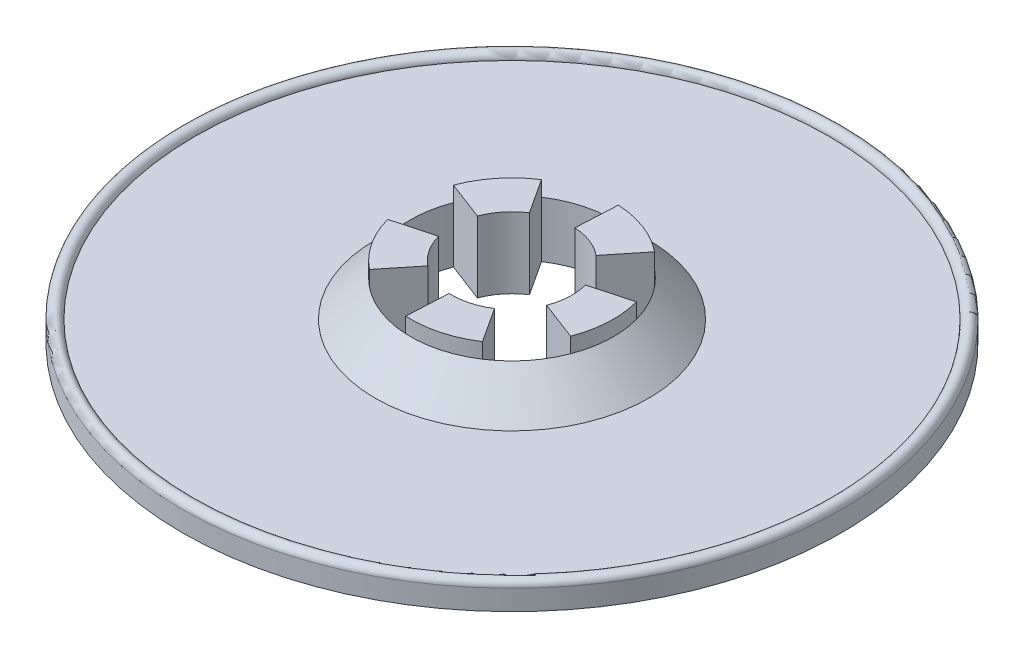
from build123d import *

# Parameters (mm, degrees)
SKETCH1_R           = 41.275
BOSS_EXTRUDE1_DEPTH = 2.54
SKETCH6_R           = 12.7
BOSS_EXTRUDE3_DEPTH = 6.35
CHAMFER2_SIZE       = 4.445
CUT_EXTRUDE2_DEPTH  = 9.89


with BuildPart() as part:
    # Sketch1 → Boss-Extrude1 (new body)
    with BuildSketch(Plane(origin=(0, 0, 0), x_dir=(1, 0, 0), z_dir=(0, 1, 0))):
        Circle(SKETCH1_R)
    extrude(amount=BOSS_EXTRUDE1_DEPTH)

    # Sketch6 → Boss-Extrude3 (add)
    with BuildSketch(Plane(origin=(0, 2.54, 0), x_dir=(1, 0, 0), z_dir=(0, 1, 0))):
        Circle(SKETCH6_R)
    extrude(amount=BOSS_EXTRUDE3_DEPTH)

    # Chamfer2
    chamfer2_edges = [part.edges().sort_by_distance(p)[0] for p in [
        (-12.7, 2.54, 0),
    ]]
    chamfer(chamfer2_edges, length=CHAMFER2_SIZE)

    # Sketch4 → Cut-Extrude2 (cut, through all)
    with BuildSketch(Plane.XZ):
        with BuildLine():
            ThreePointArc((11.86615569, 4.52596389), (9.886784934, 7.971291217), (6.939626784, 10.636333019))
            Line((6.939626784, 10.636333019), (4.098204794, 6.281299027))
            ThreePointArc((4.098204794, 6.281299027), (1.956596228, 7.240285298), (-0.376537609, 7.490541998))
            Line((-0.376537609, 7.490541998), (-0.637603684, 12.683984451))
            ThreePointArc((-0.637603684, 12.683984451), (-4.52596389, 11.86615569), (-7.971291217, 9.886784934))
            Line((-7.971291217, 9.886784934), (-4.707455443, 5.83865252))
            ThreePointArc((-4.707455443, 5.83865252), (-6.281299027, 4.098204794), (-7.240285298, 1.956596228))
            Line((-7.240285298, 1.956596228), (-12.260216438, 3.313169613))
            ThreePointArc((-12.260216438, 3.313169613), (-12.683984451, -0.637603684), (-11.86615569, -4.52596389))
            Line((-11.86615569, -4.52596389), (-7.007572258, -2.672813321))
            ThreePointArc((-7.007572258, -2.672813321), (-5.83865252, -4.707455443), (-4.098204794, -6.281299027))
            Line((-4.098204794, -6.281299027), (-6.939626784, -10.636333019))
            ThreePointArc((-6.939626784, -10.636333019), (-3.313169613, -12.260216438), (0.637603684, -12.683984451))
            Line((0.637603684, -12.683984451), (0.376537609, -7.490541998))
            ThreePointArc((0.376537609, -7.490541998), (2.672813321, -7.007572258), (4.707455443, -5.83865252))
            Line((4.707455443, -5.83865252), (7.971291217, -9.886784934))
            ThreePointArc((7.971291217, -9.886784934), (10.636333019, -6.939626784), (12.260216438, -3.313169613))
            Line((12.260216438, -3.313169613), (7.240285298, -1.956596228))
            ThreePointArc((7.240285298, -1.956596228), (7.490541998, 0.376537609), (7.007572258, 2.672813321))
            Line((7.007572258, 2.672813321), (11.86615569, 4.52596389))
        make_face()
    extrude(amount=-CUT_EXTRUDE2_DEPTH, mode=Mode.SUBTRACT)

    # Sketch7 → Revolve1 (revolve)
    with BuildSketch(Plane.XY):
        with BuildLine():
            Line((-41.275, 2.54), (-39.68496, 2.54))
            ThreePointArc((-39.68496, 2.54), (-40.47998, 3.33502), (-41.275, 2.54))
        make_face()
    revolve(axis=Axis((0, 8.001, 0), (0, -1, 0)))


solid = part.part
